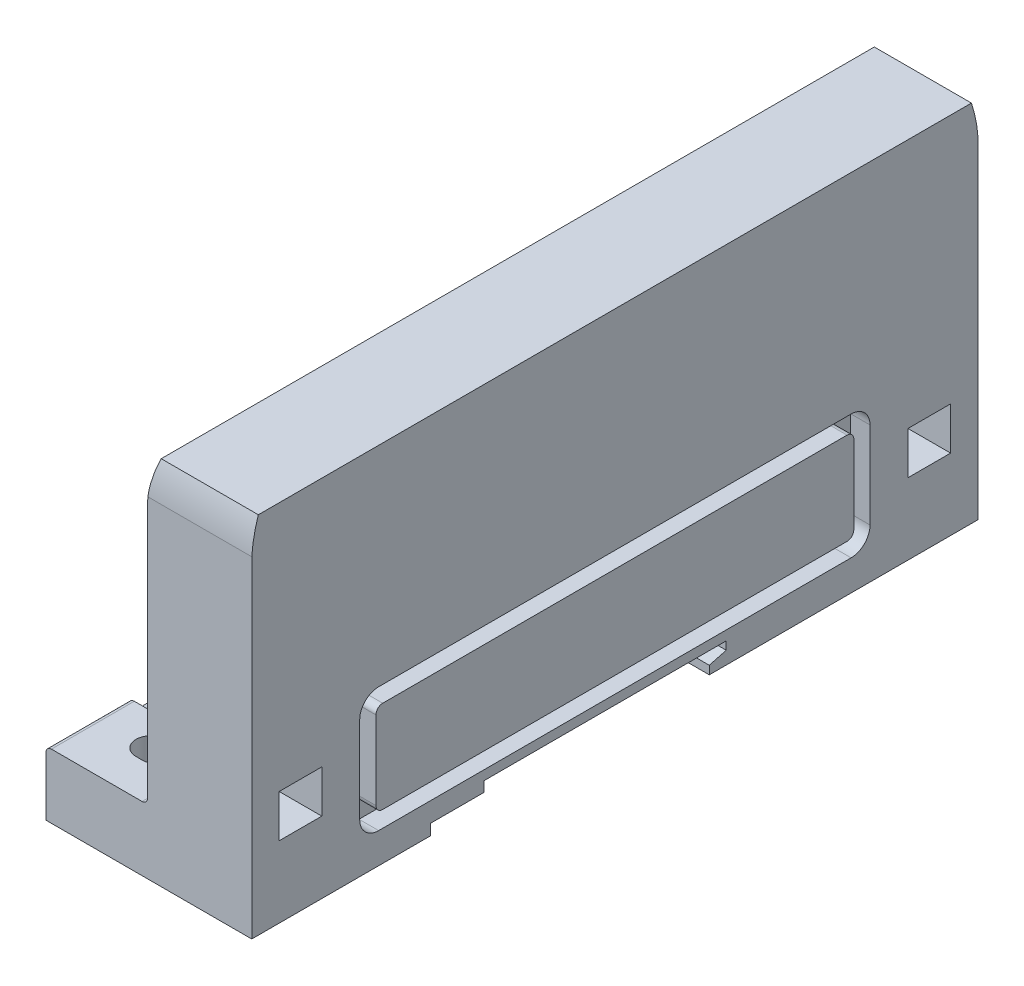
from build123d import *

# Parameters (mm, degrees)
BOSS_EXTRUDE1_DEPTH      = 53.65
BOSS_EXTRUDE1_DEPTH_BACK = 53.65
CUT_EXTRUDE1_DEPTH       = 2.9
CUT_EXTRUDE1_DEPTH_BACK  = 2.9
BOSS_EXTRUDE2_DEPTH      = 2.9
CUT_EXTRUDE2_DEPTH       = 40
CUT_EXTRUDE2_DEPTH_BACK  = 40
CUT_EXTRUDE3_DEPTH       = 40
CUT_EXTRUDE3_DEPTH_BACK  = 40
CUT_EXTRUDE4_DEPTH       = 30
CUT_EXTRUDE4_DEPTH_BACK  = 30
CUT_EXTRUDE5_DEPTH       = 30
CUT_EXTRUDE5_DEPTH_BACK  = 30
CUT_EXTRUDE6_DEPTH       = 30
CUT_EXTRUDE7_DEPTH       = 30
CUT_EXTRUDE8_DEPTH       = 30
SKETCH11_R               = 2.15
CUT_EXTRUDE9_DEPTH       = 30
CUT_EXTRUDE10_DEPTH      = 2
CUT_EXTRUDE11_DEPTH      = 2
CUT_EXTRUDE12_DEPTH      = 2
SKETCH15_W               = 6.3
SKETCH15_H               = 6.3
CUT_EXTRUDE13_DEPTH      = 9.4
SKETCH17_W               = 6.3
SKETCH17_H               = 6.3
CUT_EXTRUDE14_DEPTH      = 9.4
BOSS_EXTRUDE3_DEPTH      = 1.5
BOSS_EXTRUDE4_DEPTH      = 1.5
BOSS_EXTRUDE5_DEPTH      = 1.5
BOSS_EXTRUDE6_DEPTH      = 1.5
BOSS_EXTRUDE7_DEPTH      = 10
CUT_EXTRUDE15_DEPTH      = 2
BOSS_EXTRUDE8_DEPTH      = 1.5


with BuildPart() as part:
    # Sketch1 → Boss-Extrude1 (new, two sides: drawn at the far end of the back side and taken through both)
    with BuildSketch(Plane.XY.offset(-BOSS_EXTRUDE1_DEPTH_BACK)):
        with BuildLine():
            Line((-30.4, 10), (-30.4, 1.3))
            Line((-30.4, 1.3), (0, 1.3))
            Line((0, 1.3), (0, 55.1))
            Line((0, 55.1), (-14.348350852, 55.1))
            ThreePointArc((-14.348350852, 55.1), (-15.135336544, 51.942914042), (-15.4, 48.7))
            Line((-15.4, 48.7), (-15.4, 11.6))
            ThreePointArc((-15.4, 11.6), (-15.634314575, 11.034314575), (-16.2, 10.8))
            Line((-16.2, 10.8), (-29.6, 10.8))
            ThreePointArc((-29.6, 10.8), (-30.165685425, 10.565685425), (-30.4, 10))
        make_face()
    extrude(amount=BOSS_EXTRUDE1_DEPTH + BOSS_EXTRUDE1_DEPTH_BACK)

    # Sketch2 → Cut-Extrude1 (cut, two sides: drawn at the far end of the back side and taken through both)
    with BuildSketch(Plane(origin=(0, 0, 0), x_dir=(0, 0, -1), z_dir=(1, 0, 0)).offset(-CUT_EXTRUDE1_DEPTH_BACK)):
        with BuildLine():
            Line((-37.7, 21.4), (-37.7, 8.6))
            ThreePointArc((-37.7, 8.6), (-36.879898987, 6.620101013), (-34.9, 5.8))
            Line((-34.9, 5.8), (34.9, 5.8))
            ThreePointArc((34.9, 5.8), (36.879898987, 6.620101013), (37.7, 8.6))
            Line((37.7, 8.6), (37.7, 21.4))
            ThreePointArc((37.7, 21.4), (36.879898987, 23.379898987), (34.9, 24.2))
            Line((34.9, 24.2), (-34.9, 24.2))
            ThreePointArc((-34.9, 24.2), (-36.879898987, 23.379898987), (-37.7, 21.4))
        make_face()
    extrude(amount=CUT_EXTRUDE1_DEPTH + CUT_EXTRUDE1_DEPTH_BACK, mode=Mode.SUBTRACT)

    # Sketch3 → Boss-Extrude2 (add)
    with BuildSketch(Plane(origin=(0, 0, 0), x_dir=(0, 0, -1), z_dir=(1, 0, 0))):
        with BuildLine():
            Line((-35.3, 20.8), (-35.3, 9.2))
            ThreePointArc((-35.3, 9.2), (-35.007106781, 8.492893219), (-34.3, 8.2))
            Line((-34.3, 8.2), (34.3, 8.2))
            ThreePointArc((34.3, 8.2), (35.007106781, 8.492893219), (35.3, 9.2))
            Line((35.3, 9.2), (35.3, 20.8))
            ThreePointArc((35.3, 20.8), (35.007106781, 21.507106781), (34.3, 21.8))
            Line((34.3, 21.8), (-34.3, 21.8))
            ThreePointArc((-34.3, 21.8), (-35.007106781, 21.507106781), (-35.3, 20.8))
        make_face()
    extrude(amount=-BOSS_EXTRUDE2_DEPTH)

    # Sketch4 → Cut-Extrude2 (cut, two sides: drawn at the far end of the back side and taken through both)
    with BuildSketch(Plane(origin=(0, 0, 0), x_dir=(0, 0, -1), z_dir=(1, 0, 0)).offset(-CUT_EXTRUDE2_DEPTH_BACK)):
        with BuildLine():
            Line((-60, 30), (-53.7, 30))
            Line((-53.7, 30), (-53.7, 48.8))
            ThreePointArc((-53.7, 48.8), (-53.434627084, 52.043139925), (-52.645568263, 55.2))
            Line((-52.645568263, 55.2), (52.645568263, 55.2))
            ThreePointArc((52.645568263, 55.2), (53.434627084, 52.043139925), (53.7, 48.8))
            Line((53.7, 48.8), (53.7, 30))
            Line((53.7, 30), (60, 30))
            Line((60, 30), (60, 66))
            Line((60, 66), (-60, 66))
            Line((-60, 66), (-60, 30))
        make_face()
    extrude(amount=CUT_EXTRUDE2_DEPTH + CUT_EXTRUDE2_DEPTH_BACK, mode=Mode.SUBTRACT)

    # Sketch5 → Cut-Extrude3 (cut, two sides: drawn at the far end of the back side and taken through both)
    with BuildSketch(Plane(origin=(0, 0, 0), x_dir=(0, 0, -1), z_dir=(1, 0, 0)).offset(-CUT_EXTRUDE3_DEPTH_BACK)):
        Polygon((-27.25, -8.509379709), (13.95, -8.0873608), (13.95, 2.530127019), (16.45, 3.2), (16.45, 4.4), (-19.35, 4.4), (-19.35, 2.9), (-27.25, 2.9), align=None)
    extrude(amount=CUT_EXTRUDE3_DEPTH + CUT_EXTRUDE3_DEPTH_BACK, mode=Mode.SUBTRACT)

    # Sketch6 → Cut-Extrude4 (cut, two sides: drawn at the far end of the back side and taken through both)
    with BuildSketch(Plane(origin=(0, 0, 0), x_dir=(1, 0, 0), z_dir=(0, 1, 0)).offset(-CUT_EXTRUDE4_DEPTH_BACK)):
        with BuildLine():
            Line((-24.45, 26.9), (-22.95, 26.9))
            ThreePointArc((-22.95, 26.9), (-19.65, 30.2), (-22.95, 33.5))
            Line((-22.95, 33.5), (-24.45, 33.5))
            ThreePointArc((-24.45, 33.5), (-27.75, 30.2), (-24.45, 26.9))
        make_face()
    extrude(amount=CUT_EXTRUDE4_DEPTH + CUT_EXTRUDE4_DEPTH_BACK, mode=Mode.SUBTRACT)

    # Sketch7 → Cut-Extrude5 (cut, two sides: drawn at the far end of the back side and taken through both)
    with BuildSketch(Plane(origin=(0, 0, 0), x_dir=(1, 0, 0), z_dir=(0, 1, 0)).offset(-CUT_EXTRUDE5_DEPTH_BACK)):
        with BuildLine():
            Line((-24.45, 39.85), (-22.95, 39.85))
            ThreePointArc((-22.95, 39.85), (-19.65, 43.15), (-22.95, 46.45))
            Line((-22.95, 46.45), (-24.45, 46.45))
            ThreePointArc((-24.45, 46.45), (-27.749999867, 43.15), (-24.45, 39.85))
        make_face()
    extrude(amount=CUT_EXTRUDE5_DEPTH + CUT_EXTRUDE5_DEPTH_BACK, mode=Mode.SUBTRACT)

    # Sketch8 → Cut-Extrude6 (cut)
    with BuildSketch(Plane(origin=(0, 0, 0), x_dir=(1, 0, 0), z_dir=(0, 1, 0))):
        with BuildLine():
            Line((-24.45, -38.1), (-22.95, -38.1))
            ThreePointArc((-22.95, -38.1), (-19.65, -34.8), (-22.95, -31.5))
            Line((-22.95, -31.5), (-24.45, -31.5))
            ThreePointArc((-24.45, -31.5), (-27.75, -34.8), (-24.45, -38.1))
        make_face()
    extrude(amount=CUT_EXTRUDE6_DEPTH, mode=Mode.SUBTRACT)

    # Sketch9 → Cut-Extrude7 (cut)
    with BuildSketch(Plane(origin=(0, 0, 0), x_dir=(1, 0, 0), z_dir=(0, 1, 0))):
        with BuildLine():
            Line((-22.4, 17.95), (-21.4, 17.95))
            ThreePointArc((-21.4, 17.95), (-19.2, 20.15), (-21.4, 22.35))
            Line((-21.4, 22.35), (-22.4, 22.35))
            ThreePointArc((-22.4, 22.35), (-24.6, 20.15), (-22.4, 17.95))
        make_face()
    extrude(amount=CUT_EXTRUDE7_DEPTH, mode=Mode.SUBTRACT)

    # Sketch10 → Cut-Extrude8 (cut)
    with BuildSketch(Plane(origin=(0, 0, 0), x_dir=(1, 0, 0), z_dir=(0, 1, 0))):
        with BuildLine():
            Line((-22.4, -48.35), (-21.4, -48.35))
            ThreePointArc((-21.4, -48.35), (-19.2, -46.15), (-21.4, -43.95))
            Line((-21.4, -43.95), (-22.4, -43.95))
            ThreePointArc((-22.4, -43.95), (-24.6, -46.15), (-22.4, -48.35))
        make_face()
    extrude(amount=CUT_EXTRUDE8_DEPTH, mode=Mode.SUBTRACT)

    # Sketch11 → Cut-Extrude9 (cut)
    with BuildSketch(Plane(origin=(0, 0, 0), x_dir=(1, 0, 0), z_dir=(0, 1, 0))):
        with Locations((-21.45, -23.05)):
            Circle(SKETCH11_R)
    extrude(amount=CUT_EXTRUDE9_DEPTH, mode=Mode.SUBTRACT)

    # Sketch12 → Cut-Extrude10 (cut)
    with BuildSketch(Plane(origin=(0, 10.8, 0), x_dir=(1, 0, 0), z_dir=(0, 1, 0))):
        with BuildLine():
            Line((-31, 36.8), (-31, 23.6))
            Line((-31, 23.6), (-22.9, 23.6))
            ThreePointArc((-22.9, 23.6), (-16.300000267, 30.2), (-22.9, 36.8))
            Line((-22.9, 36.8), (-31, 36.8))
        make_face()
    extrude(amount=-CUT_EXTRUDE10_DEPTH, mode=Mode.SUBTRACT)

    # Sketch13 → Cut-Extrude11 (cut)
    with BuildSketch(Plane(origin=(0, 10.8, 0), x_dir=(1, 0, 0), z_dir=(0, 1, 0))):
        with BuildLine():
            Line((-31, 49.75), (-31, 36.55))
            Line((-31, 36.55), (-22.9, 36.55))
            ThreePointArc((-22.9, 36.55), (-16.300000267, 43.15), (-22.9, 49.75))
            Line((-22.9, 49.75), (-31, 49.75))
        make_face()
    extrude(amount=-CUT_EXTRUDE11_DEPTH, mode=Mode.SUBTRACT)

    # Sketch14 → Cut-Extrude12 (cut)
    with BuildSketch(Plane(origin=(0, 10.8, 0), x_dir=(1, 0, 0), z_dir=(0, 1, 0))):
        with BuildLine():
            Line((-31, -28.2), (-31, -41.4))
            Line((-31, -41.4), (-22.9, -41.4))
            ThreePointArc((-22.9, -41.4), (-16.300000267, -34.8), (-22.9, -28.2))
            Line((-22.9, -28.2), (-31, -28.2))
        make_face()
    extrude(amount=-CUT_EXTRUDE12_DEPTH, mode=Mode.SUBTRACT)

    # Sketch15 → Cut-Extrude13 (cut)
    with BuildSketch(Plane(origin=(0, 0, 0), x_dir=(0, 0, -1), z_dir=(1, 0, 0))):
        with Locations((46.45, 15)):
            Rectangle(SKETCH15_W, SKETCH15_H)
    extrude(amount=-CUT_EXTRUDE13_DEPTH, mode=Mode.SUBTRACT)

    # Sketch16 → Cut-Revolve1 (revolve, cut)
    with BuildSketch(Plane(origin=(0, 15, 0), x_dir=(1, 0, 0), z_dir=(0, 1, 0))):
        Polygon((-17.4, 46.45), (-17.4, 50.45), (-12.4, 50.45), (-12.4, 48.95), (-9.4, 48.95), (-9.4, 46.45), align=None)
    revolve(axis=Axis((0, 15, -46.45), (-1, 0, 0)), mode=Mode.SUBTRACT)

    # Sketch17 → Cut-Extrude14 (cut)
    with BuildSketch(Plane(origin=(0, 0, 0), x_dir=(0, 0, -1), z_dir=(1, 0, 0))):
        with Locations((-46.45, 15)):
            Rectangle(SKETCH17_W, SKETCH17_H)
    extrude(amount=-CUT_EXTRUDE14_DEPTH, mode=Mode.SUBTRACT)

    # Sketch18 → Cut-Revolve2 (revolve, cut)
    with BuildSketch(Plane(origin=(0, 15, 0), x_dir=(1, 0, 0), z_dir=(0, 1, 0))):
        Polygon((-17.4, -46.45), (-17.4, -42.45), (-12.4, -42.45), (-12.4, -43.95), (-9.4, -43.95), (-9.4, -46.45), align=None)
    revolve(axis=Axis((0, 15, 46.45), (-1, 0, 0)), mode=Mode.SUBTRACT)

    # Sketch19 → Boss-Extrude3 (add)
    with BuildSketch(Plane(origin=(0, 0, 0), x_dir=(1, 0, 0), z_dir=(0, 1, 0))):
        with BuildLine():
            Line((-22.4, -49.85), (-21.4, -49.85))
            ThreePointArc((-21.4, -49.85), (-17.7, -46.15), (-21.4, -42.45))
            Line((-21.4, -42.45), (-22.4, -42.45))
            ThreePointArc((-22.4, -42.45), (-26.1, -46.15), (-22.4, -49.85))
        make_face()
        with BuildLine():
            Line((-22.4, -48.35), (-21.4, -48.35))
            ThreePointArc((-21.4, -48.35), (-19.2, -46.15), (-21.4, -43.95))
            Line((-21.4, -43.95), (-22.4, -43.95))
            ThreePointArc((-22.4, -43.95), (-24.6, -46.15), (-22.4, -48.35))
        make_face(mode=Mode.SUBTRACT)
    extrude(amount=BOSS_EXTRUDE3_DEPTH)

    # Sketch20 → Boss-Extrude4 (add)
    with BuildSketch(Plane(origin=(0, 0, 0), x_dir=(1, 0, 0), z_dir=(0, 1, 0))):
        with BuildLine():
            Line((-24.45, -40.1), (-22.95, -40.1))
            ThreePointArc((-22.95, -40.1), (-17.649999897, -34.8), (-22.95, -29.5))
            Line((-22.95, -29.5), (-24.45, -29.5))
            ThreePointArc((-24.45, -29.5), (-29.75, -34.8), (-24.45, -40.1))
        make_face()
        with BuildLine():
            Line((-24.45, -38.1), (-22.95, -38.1))
            ThreePointArc((-22.95, -38.1), (-19.649999897, -34.8), (-22.95, -31.5))
            Line((-22.95, -31.5), (-24.45, -31.5))
            ThreePointArc((-24.45, -31.5), (-27.75, -34.8), (-24.45, -38.1))
        make_face(mode=Mode.SUBTRACT)
    extrude(amount=BOSS_EXTRUDE4_DEPTH)

    # Sketch21 → Boss-Extrude5 (add)
    with BuildSketch(Plane(origin=(0, 0, 0), x_dir=(1, 0, 0), z_dir=(0, 1, 0))):
        with BuildLine():
            Line((-24.45, 24.9), (-22.95, 24.9))
            ThreePointArc((-22.95, 24.9), (-17.649999897, 30.2), (-22.95, 35.5))
            Line((-22.95, 35.5), (-24.45, 35.5))
            ThreePointArc((-24.45, 35.5), (-29.75, 30.2), (-24.45, 24.9))
        make_face()
        with BuildLine():
            Line((-24.45, 26.9), (-22.95, 26.9))
            ThreePointArc((-22.95, 26.9), (-19.649999897, 30.2), (-22.95, 33.5))
            Line((-22.95, 33.5), (-24.45, 33.5))
            ThreePointArc((-24.45, 33.5), (-27.75, 30.2), (-24.45, 26.9))
        make_face(mode=Mode.SUBTRACT)
    extrude(amount=BOSS_EXTRUDE5_DEPTH)

    # Sketch22 → Boss-Extrude6 (add)
    with BuildSketch(Plane(origin=(0, 0, 0), x_dir=(1, 0, 0), z_dir=(0, 1, 0))):
        with BuildLine():
            Line((-24.45, 37.85), (-22.95, 37.85))
            ThreePointArc((-22.95, 37.85), (-17.649999897, 43.15), (-22.95, 48.45))
            Line((-22.95, 48.45), (-24.45, 48.45))
            ThreePointArc((-24.45, 48.45), (-29.75, 43.15), (-24.45, 37.85))
        make_face()
        with BuildLine():
            Line((-24.45, 39.85), (-22.95, 39.85))
            ThreePointArc((-22.95, 39.85), (-19.649999897, 43.15), (-22.95, 46.45))
            Line((-22.95, 46.45), (-24.45, 46.45))
            ThreePointArc((-24.45, 46.45), (-27.75, 43.15), (-24.45, 39.85))
        make_face(mode=Mode.SUBTRACT)
    extrude(amount=BOSS_EXTRUDE6_DEPTH)

    # Sketch23 → Revolve1 (revolve)
    with BuildSketch(Plane.XY.offset(-4)):
        Polygon((-22.55, 11.3), (-18.55, 11.3), (-18.05, 10.8), (-22.55, 10.8), align=None)
    revolve(axis=Axis((-22.55, 10.8, -4), (0, 1, 0)))

    # Sketch24 → Revolve2 (revolve)
    with BuildSketch(Plane.XY.offset(-4)):
        with BuildLine():
            Line((-22.55, 15.385), (-21.983442533, 15.385))
            Line((-21.983442533, 15.385), (-20.251391725, 16.385))
            ThreePointArc((-20.251391725, 16.385), (-19.364587721, 15.97096405), (-18.55, 15.428475383))
            Line((-18.55, 15.428475383), (-18.55, 13.8))
            Line((-18.55, 13.8), (-20.55, 13.8))
            Line((-20.55, 13.8), (-20.55, 13.7))
            Line((-20.55, 13.7), (-18.55, 13.7))
            Line((-18.55, 13.7), (-18.05, 13.2))
            Line((-18.05, 13.2), (-18.05, 12.8))
            Line((-18.05, 12.8), (-18.55, 12.8))
            Line((-18.55, 12.8), (-18.55, 11.3))
            Line((-18.55, 11.3), (-22.55, 11.3))
            Line((-22.55, 11.3), (-22.55, 15.385))
        make_face()
    revolve(axis=Axis((-22.55, 11.3, -4), (0, 1, 0)))

    # Sketch25 → Boss-Extrude7 (add)
    with BuildSketch(Plane(origin=(-22.55, 0, 0), x_dir=(0, 0, -1), z_dir=(1, 0, 0))):
        Polygon((-0.5, 10.8), (8.5, 10.8), (8, 11.3), (0, 11.3), align=None)
    extrude(amount=BOSS_EXTRUDE7_DEPTH)

    # Sketch26 → Cut-Extrude15 (cut)
    with BuildSketch(Plane(origin=(0, 15.385, 0), x_dir=(1, 0, 0), z_dir=(0, 1, 0))):
        with BuildLine():
            ThreePointArc((-24.40940169, 3.429818182), (-24.489896901, 2.879999994), (-23.973492772, 2.674801814))
            ThreePointArc((-23.973492772, 2.674801814), (-23.356749485, 2.602668891), (-22.985908906, 2.104619992))
            ThreePointArc((-22.985908906, 2.104619992), (-22.550000009, 1.76), (-22.114091099, 2.104619975))
            ThreePointArc((-22.114091099, 2.104619975), (-21.743250517, 2.60266889), (-21.126507216, 2.67480181))
            ThreePointArc((-21.126507216, 2.67480181), (-20.6101031, 2.879999992), (-20.690598298, 3.42981817))
            ThreePointArc((-20.690598298, 3.42981817), (-20.93650102, 3.999999991), (-20.69059831, 4.570181818))
            ThreePointArc((-20.69059831, 4.570181818), (-20.610103096, 5.12), (-21.126507216, 5.32519819))
            ThreePointArc((-21.126507216, 5.32519819), (-21.743250516, 5.39733111), (-22.114091098, 5.895380023))
            ThreePointArc((-22.114091098, 5.895380023), (-22.550000016, 6.24), (-22.98590891, 5.895379991))
            ThreePointArc((-22.98590891, 5.895379991), (-23.356749498, 5.397331102), (-23.973492784, 5.32519819))
            ThreePointArc((-23.973492784, 5.32519819), (-24.489896906, 5.119999997), (-24.409401684, 4.570181813))
            ThreePointArc((-24.409401684, 4.570181813), (-24.16349898, 3.999999996), (-24.40940169, 3.429818182))
        make_face()
    extrude(amount=CUT_EXTRUDE15_DEPTH, mode=Mode.SUBTRACT)

    # Sketch27 → Boss-Extrude8 (add)
    with BuildSketch(Plane(origin=(0, 0, 0), x_dir=(1, 0, 0), z_dir=(0, 1, 0))):
        with BuildLine():
            Line((-22.4, 16.45), (-21.4, 16.45))
            ThreePointArc((-21.4, 16.45), (-17.7, 20.15), (-21.4, 23.85))
            Line((-21.4, 23.85), (-22.4, 23.85))
            ThreePointArc((-22.4, 23.85), (-26.1, 20.15), (-22.4, 16.45))
        make_face()
        with BuildLine():
            Line((-22.4, 17.95), (-21.4, 17.95))
            ThreePointArc((-21.4, 17.95), (-19.2, 20.15), (-21.4, 22.35))
            Line((-21.4, 22.35), (-22.4, 22.35))
            ThreePointArc((-22.4, 22.35), (-24.6, 20.15), (-22.4, 17.95))
        make_face(mode=Mode.SUBTRACT)
    extrude(amount=BOSS_EXTRUDE8_DEPTH)


solid = part.part
